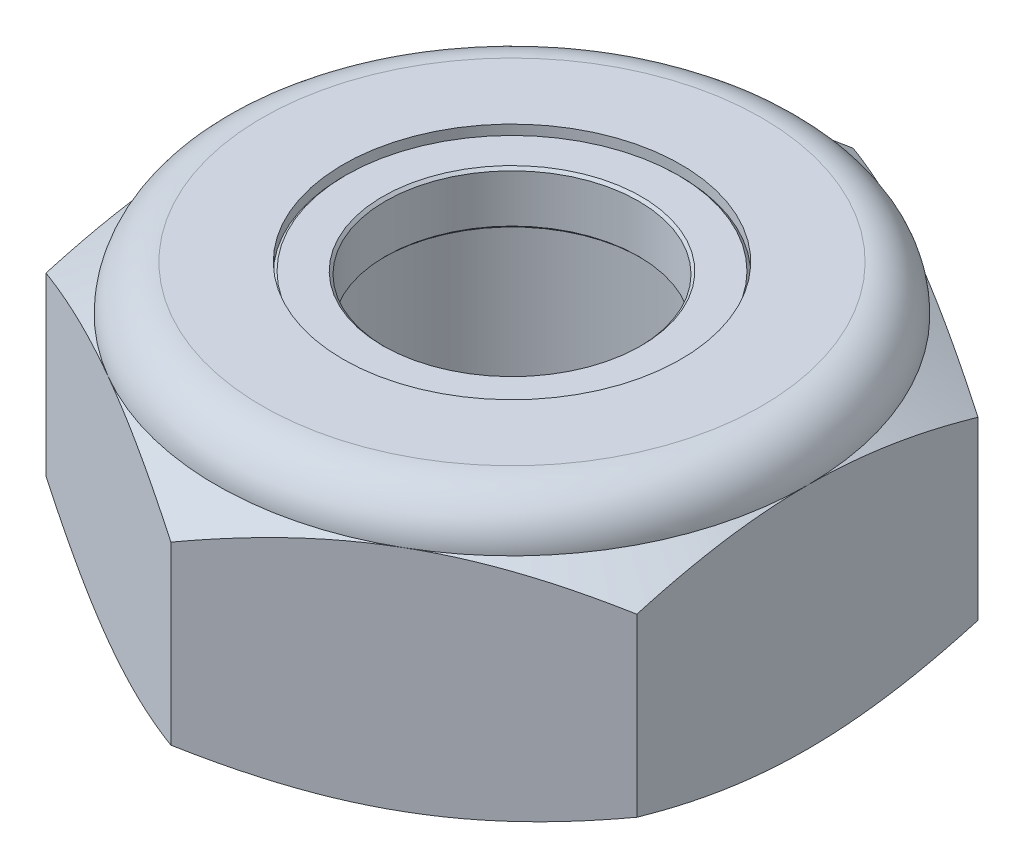
from build123d import *

# Parameters (mm, degrees)
SKETCH1_R           = 3.175
EXTRUDE1_DEPTH      = 5.159375
EXTRUDE_THIN1_START = -0.15
SKETCH3_R           = 3.175
SKETCH3_R_2         = 2.38125
EXTRUDE_THIN1_DEPTH = 1
CHAMFER1_SIZE       = 0.05


with BuildPart() as part:
    # Sketch1 → Extrude1 (new body)
    with BuildSketch(Plane(origin=(0, 0, 0), x_dir=(1, 0, 0), z_dir=(0, 1, 0))):
        Polygon((0, 6.415804866), (-5.55625, 3.207902433), (-5.55625, -3.207902433), (0, -6.415804866), (5.55625, -3.207902433), (5.55625, 3.207902433), align=None)
        Circle(SKETCH1_R, mode=Mode.SUBTRACT)
    extrude(amount=EXTRUDE1_DEPTH)

    # Sketch2 → Cut-Revolve1 (revolve, cut)
    with BuildSketch(Plane(origin=(0, 0, 0), x_dir=(0, 0, -1), z_dir=(1, 0, 0))):
        with BuildLine():
            Line((6.415804866, 5.159375), (6.415804866, 3.803214933))
            Line((6.415804866, 3.803214933), (5.55625, 4.299479167))
            ThreePointArc((5.55625, 4.299479167), (5.304392342, 4.907517342), (4.696354167, 5.159375))
            Line((4.696354167, 5.159375), (6.415804866, 5.159375))
        make_face()
        Polygon((6.415804866, 0.496264233), (5.55625, 0), (6.415804866, 0), align=None)
    revolve(axis=Axis((0, 0, 0), (0, 1, 0)), mode=Mode.SUBTRACT)


with BuildPart() as body_2:
    # Sketch3 → Extrude-Thin1 (new body)
    with BuildSketch(Plane(origin=(0, 5.159375, 0), x_dir=(1, 0, 0), z_dir=(0, 1, 0)).offset(EXTRUDE_THIN1_START)):
        Circle(SKETCH3_R)
        Circle(SKETCH3_R_2, mode=Mode.SUBTRACT)
    extrude(amount=-EXTRUDE_THIN1_DEPTH)

    # Chamfer1
    chamfer1_edges = [body_2.edges().sort_by_distance(p)[0] for p in [
        (-3.175, 5.009375, 0),
        (-2.38125, 5.009375, 0),
        (-3.175, 4.009375, 0),
        (-2.38125, 4.009375, 0),
    ]]
    chamfer(chamfer1_edges, length=CHAMFER1_SIZE)


solid = Compound([part.part, body_2.part])
